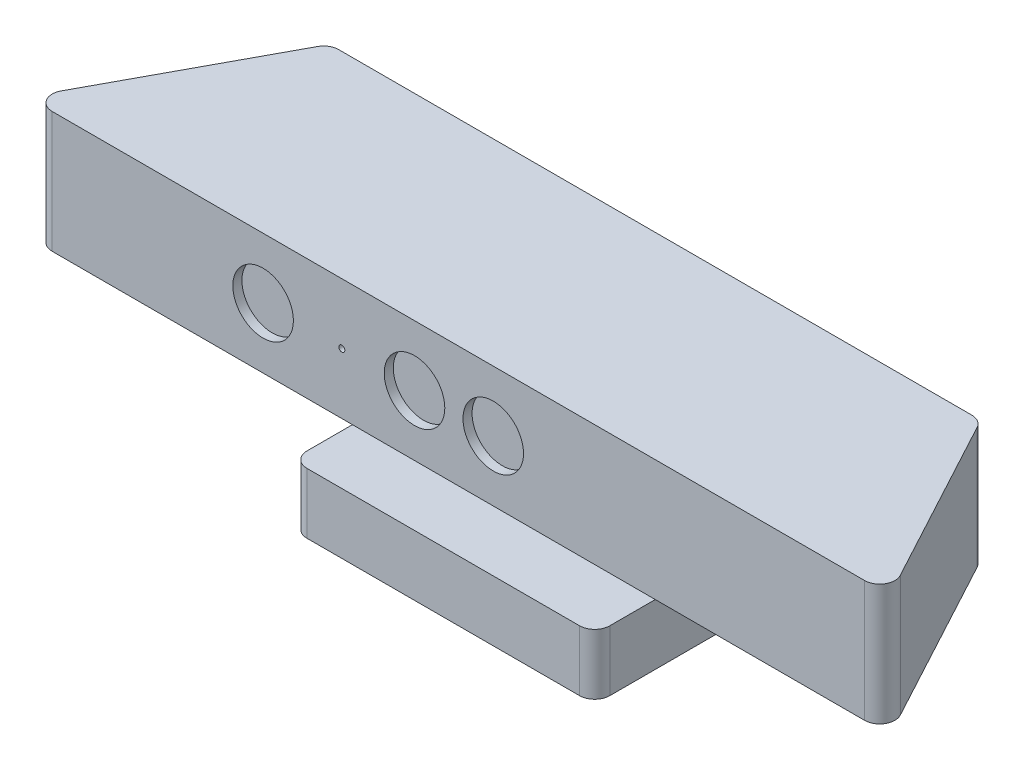
from build123d import *

# Parameters (mm, degrees)
BOSS_EXTRUDE1_DEPTH = 40
SKETCH3_R           = 10
SKETCH3_R_2         = 1
CUT_EXTRUDE1_DEPTH  = 3
SKETCH8_R           = 10
BOSS_EXTRUDE2_DEPTH = 15
SKETCH9_W           = 100
SKETCH9_H           = 75
BOSS_EXTRUDE3_DEPTH = 20
FILLET2_R           = 5
FILLET3_R           = 5


with BuildPart() as part:
    # Sketch2 → Boss-Extrude1 (new body)
    with BuildSketch(Plane(origin=(0, 0, 0), x_dir=(1, 0, 0), z_dir=(0, 1, 0))):
        Polygon((-107.5, -15.741355231), (107.5, -15.741355231), (142.5, -80.741355231), (-142.5, -80.741355231), align=None)
    extrude(amount=BOSS_EXTRUDE1_DEPTH)

    # Sketch3 → Cut-Extrude1 (cut)
    with BuildSketch(Plane.XY.offset(80.741355231)):
        with Locations((-64.5, 20)):
            Circle(SKETCH3_R)
        with Locations((-38.5, 20)):
            Circle(SKETCH3_R_2)
        with Locations((-14.5, 20)):
            Circle(SKETCH3_R)
        with Locations((11.5, 20)):
            Circle(SKETCH3_R)
    extrude(amount=-CUT_EXTRUDE1_DEPTH, mode=Mode.SUBTRACT)

    # Sketch8 → Boss-Extrude2 (add)
    with BuildSketch(Plane.XZ):
        with Locations((0, 48.241355231)):
            Circle(SKETCH8_R)
    extrude(amount=BOSS_EXTRUDE2_DEPTH)

    # Sketch9 → Boss-Extrude3 (add)
    with BuildSketch(Plane.XZ.offset(15)):
        with Locations((0, 48.241355231)):
            Rectangle(SKETCH9_W, SKETCH9_H)
    extrude(amount=BOSS_EXTRUDE3_DEPTH)

    # Fillet2
    fillet2_edges = [part.edges().sort_by_distance(p)[0] for p in [
        (-142.5, 20, 80.741355231),
        (-107.5, 20, 15.741355231),
        (107.5, 20, 15.741355231),
        (142.5, 20, 80.741355231),
    ]]
    fillet(fillet2_edges, radius=FILLET2_R)

    # Fillet3
    fillet3_edges = [part.edges().sort_by_distance(p)[0] for p in [
        (50, -25, 10.741355231),
        (50, -25, 85.741355231),
        (-50, -25, 85.741355231),
        (-50, -25, 10.741355231),
    ]]
    fillet(fillet3_edges, radius=FILLET3_R)


solid = part.part
